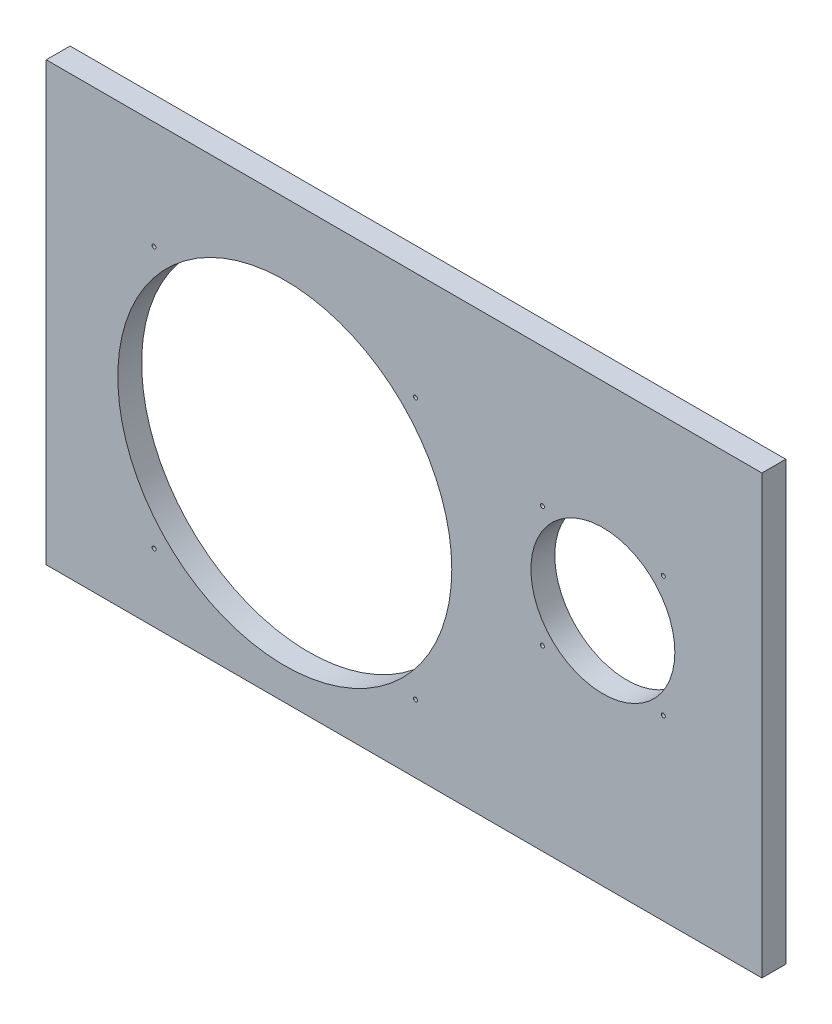
from build123d import *

# Parameters (mm, degrees)
SKETCH1_W           = 180
SKETCH1_H           = 110
SKETCH1_R           = 42
SKETCH1_R_2         = 18.1
BOSS_EXTRUDE1_DEPTH = 6
SKETCH3_R           = 0.5
CUT_EXTRUDE1_DEPTH  = 30


with BuildPart() as part:
    # Sketch1 → Boss-Extrude1 (new body)
    with BuildSketch(Plane.XY):
        with Locations((90, 55)):
            Rectangle(SKETCH1_W, SKETCH1_H)
        with Locations((60, 50)):
            Circle(SKETCH1_R, mode=Mode.SUBTRACT)
        with Locations((140, 60)):
            Circle(SKETCH1_R_2, mode=Mode.SUBTRACT)
    extrude(amount=BOSS_EXTRUDE1_DEPTH)

    # Sketch3 → Cut-Extrude1 (cut)
    with BuildSketch(Plane.XY):
        with Locations((92.880465325, 82.880465325)):
            Circle(SKETCH3_R)
        with Locations((27.119534675, 82.880465325)):
            Circle(SKETCH3_R)
        with Locations((27.119534675, 17.119534675)):
            Circle(SKETCH3_R)
        with Locations((92.880465325, 17.119534675)):
            Circle(SKETCH3_R)
        with Locations((155.202795796, 75.202795796)):
            Circle(SKETCH3_R)
        with Locations((124.797204204, 75.202795796)):
            Circle(SKETCH3_R)
        with Locations((124.797204204, 44.797204204)):
            Circle(SKETCH3_R)
        with Locations((155.202795796, 44.797204204)):
            Circle(SKETCH3_R)
    extrude(amount=CUT_EXTRUDE1_DEPTH, mode=Mode.SUBTRACT)


solid = part.part
